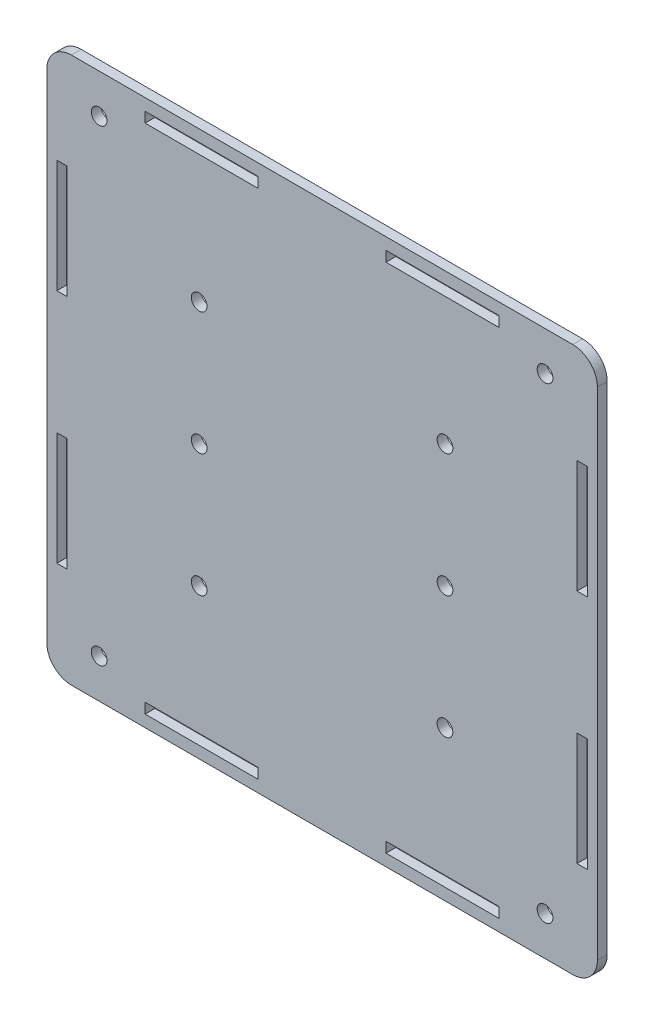
from build123d import *

# Parameters (mm, degrees)
SKETCH_1_W          = 112
SKETCH_1_H          = 111
EXTRUDE_1_DEPTH     = 2
SKETCH_2_R          = 1.6
CUT_EXTRUDE_1_DEPTH = 3
SKETCH_3_W          = 2.1
SKETCH_3_H          = 23
SKETCH_3_W_2        = 23
SKETCH_3_H_2        = 2.1
CUT_EXTRUDE_2_DEPTH = 3
SKETCH_4_R          = 1.6
CUT_EXTRUDE_3_DEPTH = 3
FILLET_1_R          = 5


with BuildPart() as part:
    # 草图1 → 凸台-拉伸1 (new body)
    with BuildSketch(Plane.XY):
        Rectangle(SKETCH_1_W, SKETCH_1_H)
    extrude(amount=EXTRUDE_1_DEPTH)

    # 草图2 → 切除-拉伸1 (cut, through all)
    with BuildSketch(Plane(origin=(0, 0, 0), x_dir=(-1, 0, 0), z_dir=(0, 0, -1))):
        with Locations((-45.35, -47.55)):
            Circle(SKETCH_2_R)
        with Locations((45.35, -47.55)):
            Circle(SKETCH_2_R)
        with Locations((45.35, 47.55)):
            Circle(SKETCH_2_R)
        with Locations((-45.35, 47.55)):
            Circle(SKETCH_2_R)
    extrude(amount=-CUT_EXTRUDE_1_DEPTH, mode=Mode.SUBTRACT)

    # 草图3 → 切除-拉伸2 (cut, through all)
    with BuildSketch(Plane(origin=(0, 0, 0), x_dir=(-1, 0, 0), z_dir=(0, 0, -1))):
        with Locations((-52.9, 24)):
            Rectangle(SKETCH_3_W, SKETCH_3_H)
        with Locations((-52.9, -24)):
            Rectangle(SKETCH_3_W, SKETCH_3_H)
        with Locations((52.9, -24)):
            Rectangle(SKETCH_3_W, SKETCH_3_H)
        with Locations((52.9, 24)):
            Rectangle(SKETCH_3_W, SKETCH_3_H)
        with Locations((-24.5, -52.05)):
            Rectangle(SKETCH_3_W_2, SKETCH_3_H_2)
        with Locations((24.5, -52.05)):
            Rectangle(SKETCH_3_W_2, SKETCH_3_H_2)
        with Locations((24.5, 52.05)):
            Rectangle(SKETCH_3_W_2, SKETCH_3_H_2)
        with Locations((-24.5, 52.05)):
            Rectangle(SKETCH_3_W_2, SKETCH_3_H_2)
    extrude(amount=-CUT_EXTRUDE_2_DEPTH, mode=Mode.SUBTRACT)

    # 草图4 → 切除-拉伸3 (cut, through all)
    with BuildSketch(Plane(origin=(0, 0, 0), x_dir=(-1, 0, 0), z_dir=(0, 0, -1))):
        with Locations((-25, -25)):
            Circle(SKETCH_4_R)
        with Locations((25, -25)):
            Circle(SKETCH_4_R)
        with Locations((25, 0)):
            Circle(SKETCH_4_R)
        with Locations((25, 25)):
            Circle(SKETCH_4_R)
        with Locations((-25, 0)):
            Circle(SKETCH_4_R)
        with Locations((-25, 25)):
            Circle(SKETCH_4_R)
    extrude(amount=-CUT_EXTRUDE_3_DEPTH, mode=Mode.SUBTRACT)

    # 圆角1
    fillet_1_edges = [part.edges().sort_by_distance(p)[0] for p in [
        (56, -55.5, 1),
        (-56, -55.5, 1),
        (-56, 55.5, 1),
        (56, 55.5, 1),
    ]]
    fillet(fillet_1_edges, radius=FILLET_1_R)


solid = part.part
